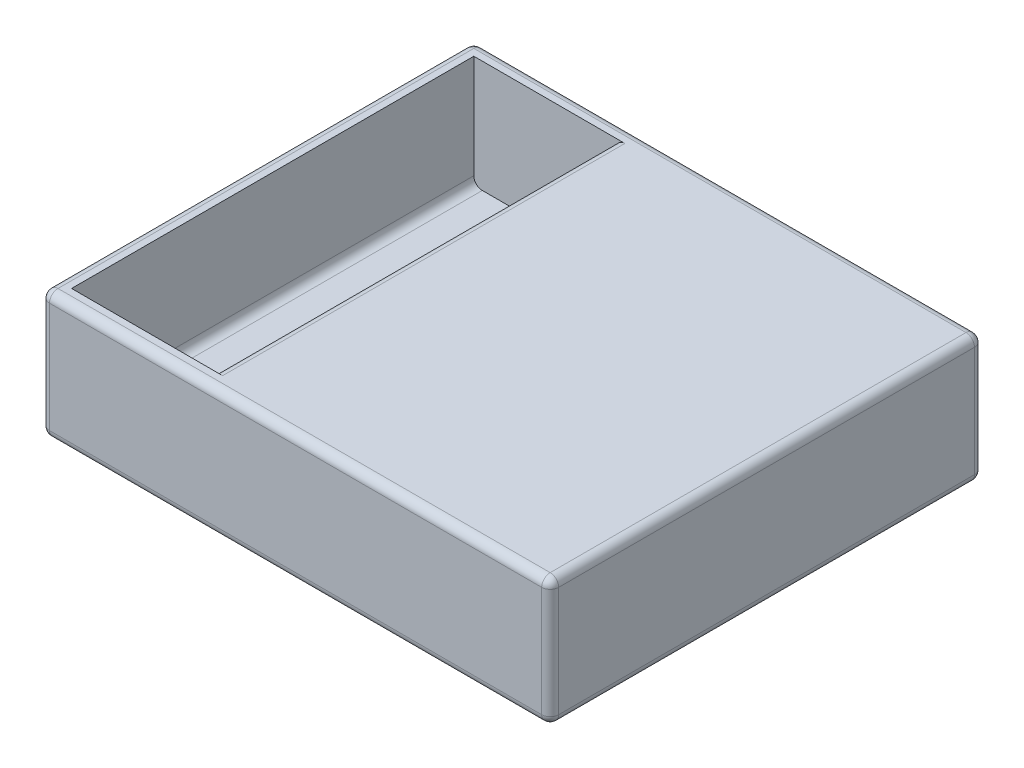
from build123d import *

# Parameters (mm, degrees)
SKETCH1_R           = 2.5
BOSS_EXTRUDE1_DEPTH = 25
SKETCH5_W           = 94
SKETCH5_H           = 79
CUT_EXTRUDE2_DEPTH  = 22
SKETCH7_W           = 85
SKETCH7_H           = 2
BOSS_EXTRUDE4_DEPTH = 66
SKETCH8_R           = 6.7
CUT_EXTRUDE3_DEPTH  = 11
FILLET1_R           = 1.67
SKETCH9_R           = 1.5
SKETCH9_R_2         = 1.2
CUT_EXTRUDE4_DEPTH  = 10


with BuildPart() as part:
    # Sketch1 → Boss-Extrude1 (new body)
    with BuildSketch(Plane(origin=(0, 0, 0), x_dir=(1, 0, 0), z_dir=(0, 1, 0))):
        Polygon((-65, 45), (-65, 37.5), (-65, -32.5), (-65, -40), (35, -40), (35, -32.5), (35, 37.5), (35, 45), align=None)
        with Locations((-25, -17.5)):
            Circle(SKETCH1_R, mode=Mode.SUBTRACT)
        with Locations((25, -17.5)):
            Circle(SKETCH1_R, mode=Mode.SUBTRACT)
        with Locations((-25, 17.5)):
            Circle(SKETCH1_R, mode=Mode.SUBTRACT)
        with Locations((25, 17.5)):
            Circle(SKETCH1_R, mode=Mode.SUBTRACT)
    extrude(amount=BOSS_EXTRUDE1_DEPTH)

    # Sketch5 → Cut-Extrude2 (cut)
    with BuildSketch(Plane(origin=(0, 25, 0), x_dir=(1, 0, 0), z_dir=(0, 1, 0))):
        with Locations((-15, 2.5)):
            Rectangle(SKETCH5_W, SKETCH5_H)
    extrude(amount=-CUT_EXTRUDE2_DEPTH, mode=Mode.SUBTRACT)

    # Sketch7 → Boss-Extrude4 (add)
    with BuildSketch(Plane.ZY.offset(-32)):
        with Locations((-2.5, 24)):
            Rectangle(SKETCH7_W, SKETCH7_H)
    extrude(amount=BOSS_EXTRUDE4_DEPTH)

    # Sketch8 → Cut-Extrude3 (cut)
    with BuildSketch(Plane.XZ):
        with Locations((0, -35.492425409)):
            Circle(SKETCH8_R)
    extrude(amount=-CUT_EXTRUDE3_DEPTH, mode=Mode.SUBTRACT)

    # Fillet1
    fillet1_edges = [part.edges().sort_by_distance(p)[0] for p in [
        (-15, 0, -45),
        (35, 0, -2.5),
        (-15, 0, 40),
        (-65, 0, -2.5),
        (-65, 12.5, -45),
        (35, 12.5, -45),
        (35, 12.5, 40),
        (-65, 12.5, 40),
        (-65, 25, -2.5),
        (32, 3, -2.5),
        (-62, 3, -2.5),
        (-15, 25, 40),
        (35, 25, -2.5),
        (-15, 25, -45),
        (-34, 25, -2.5),
    ]]
    fillet(fillet1_edges, radius=FILLET1_R)

    # Sketch9 → Cut-Extrude4 (cut)
    with BuildSketch(Plane(origin=(0, 3, 0), x_dir=(1, 0, 0), z_dir=(0, 1, 0))):
        with Locations((-48.33, 2.5)):
            Circle(SKETCH9_R)
        with Locations((-48.33, 30.3)):
            Circle(SKETCH9_R_2)
        with Locations((-48.33, -25.3)):
            Circle(SKETCH9_R_2)
    extrude(amount=-CUT_EXTRUDE4_DEPTH, mode=Mode.SUBTRACT)


solid = part.part
